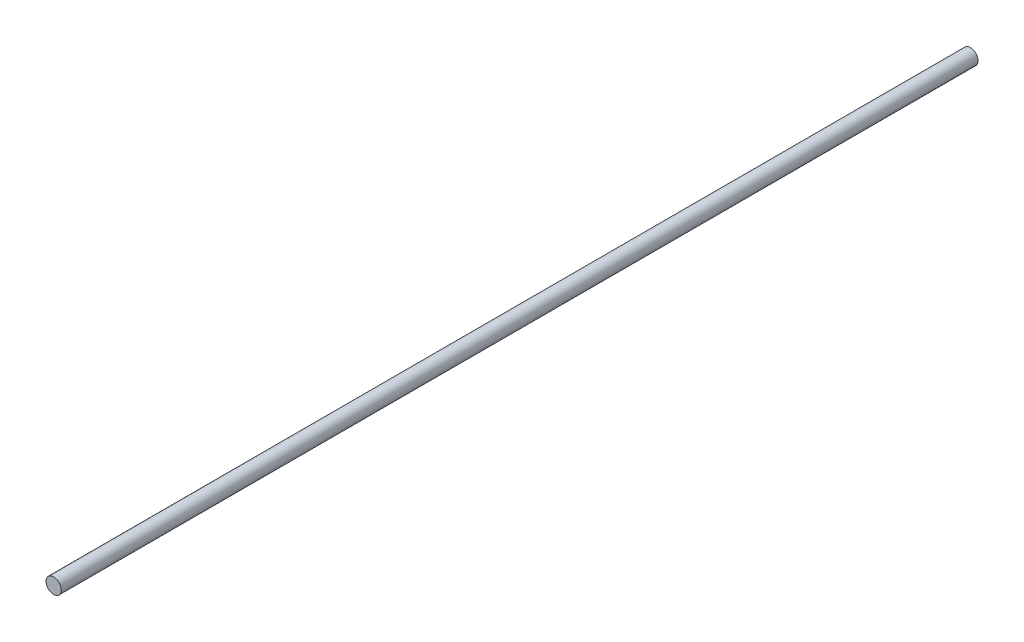
from build123d import *

# Parameters (mm, degrees)
CROQUIS1_R              = 1.5
SALIENTE_EXTRUIR1_DEPTH = 180


with BuildPart() as part:
    # Croquis1 → Saliente-Extruir1 (new body)
    with BuildSketch(Plane.XY):
        Circle(CROQUIS1_R)
    extrude(amount=SALIENTE_EXTRUIR1_DEPTH)


solid = part.part
